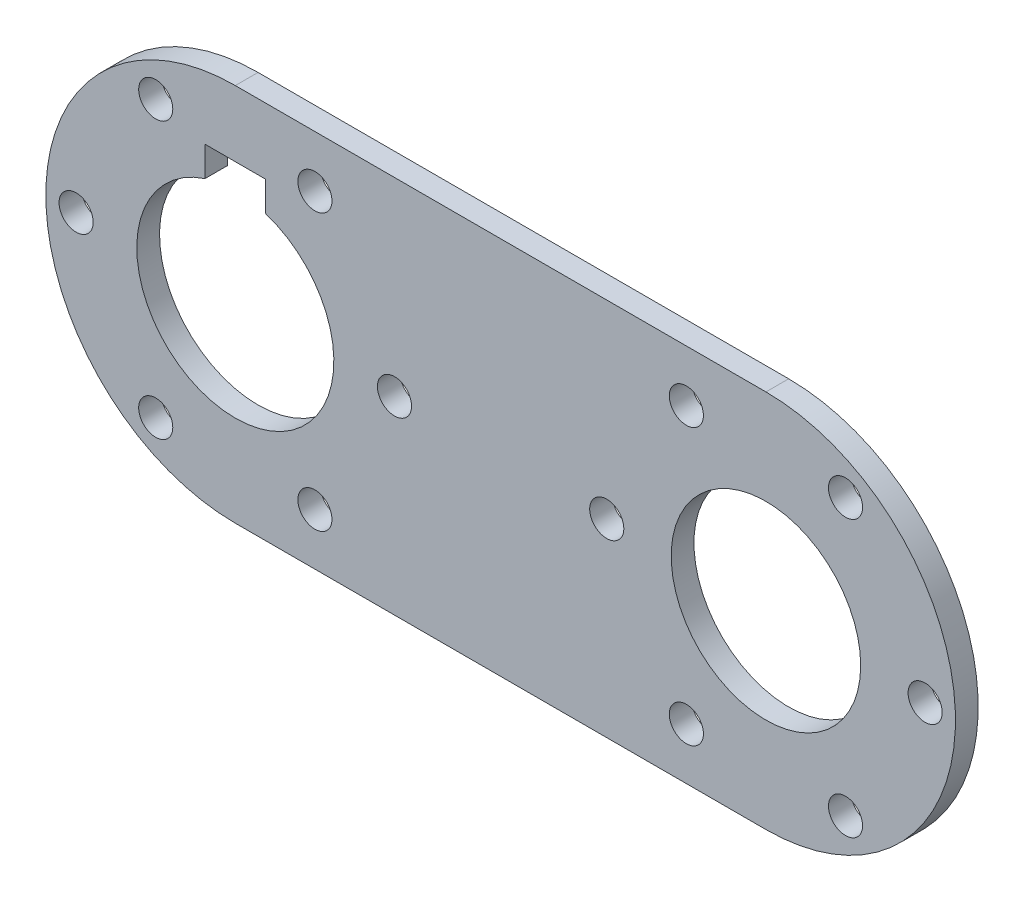
from build123d import *

# Parameters (mm, degrees)
CROQUIS1_R                   = 12.5
SALIENTE_EXTRUIR1_DEPTH      = 3
TALADRO_DE_MARGEN_PARA_M42_D = 4.5
KEYWAY_DEPTH                 = 4


with BuildPart() as part:
    # Croquis1 → Saliente-Extruir1 (new body)
    with BuildSketch(Plane.XY):
        with BuildLine():
            Line((70, 25), (0, 25))
            ThreePointArc((0, 25), (-25, 0), (0, -25))
            Line((0, -25), (70, -25))
            ThreePointArc((70, -25), (95, 0), (70, 25))
        make_face()
        with Locations((70, 0)):
            Circle(CROQUIS1_R, mode=Mode.SUBTRACT)
    extrude(amount=SALIENTE_EXTRUIR1_DEPTH)

    # Taladro de margen para M42 (through all)
    with Locations(Plane.XY.offset(3)):
        with Locations((-21, 0), (91, 0), (-10.5, 18.186533479), (10.5, 18.186533479), (21, 0), (10.5, -18.186533479), (-10.5, -18.186533479), (80.5, -18.186533479), (59.5, -18.186533479), (49, 0), (59.5, 18.186533479), (80.5, 18.186533479)):
            Hole(TALADRO_DE_MARGEN_PARA_M42_D / 2)

    # KeySketch → Keyway (cut, through all)
    with BuildSketch(Plane(origin=(0.837491084, -0.474467987, 3), x_dir=(1, 0, 0), z_dir=(0, 0, 1))):
        with BuildLine():
            Line((-4.837491084, 12.843784864), (-4.837491084, 16.774467987))
            Line((-4.837491084, 16.774467987), (3.162508916, 16.774467987))
            Line((3.162508916, 16.774467987), (3.162508916, 12.843784864))
            ThreePointArc((3.162508916, 12.843784864), (-0.837491084, -12.525532013), (-4.837491084, 12.843784864))
        make_face()
    extrude(amount=-KEYWAY_DEPTH, mode=Mode.SUBTRACT)


solid = part.part
